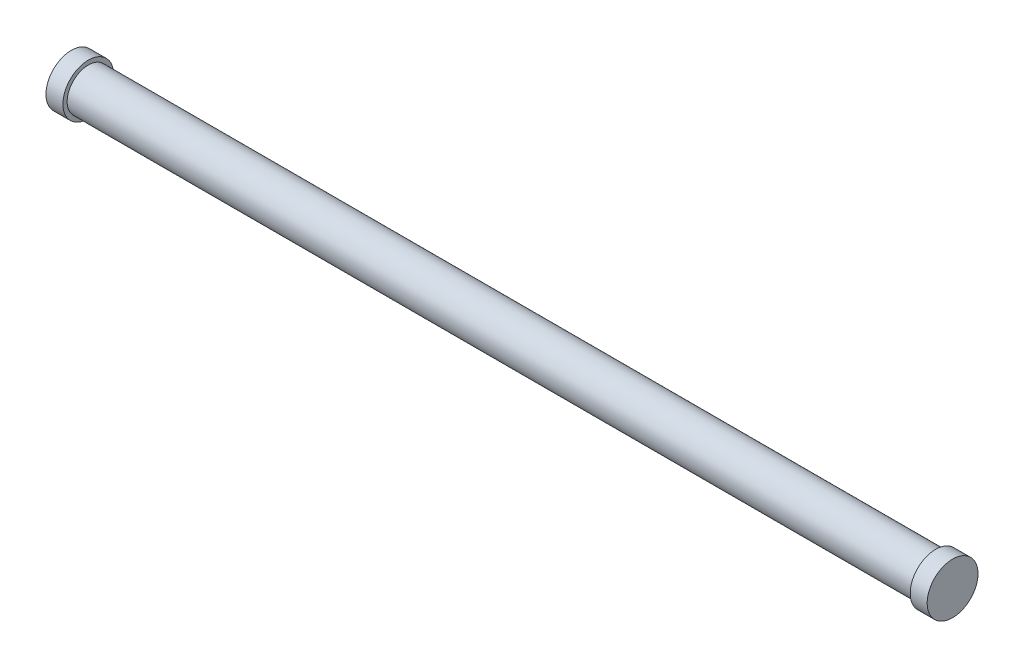
from build123d import *

# Parameters (mm, degrees)
SKETCH1_R           = 0.762
BOSS_EXTRUDE1_DEPTH = 0.508
SKETCH2_R           = 0.635
BOSS_EXTRUDE2_DEPTH = 25.4
SKETCH3_R           = 0.762
BOSS_EXTRUDE3_DEPTH = 0.508


with BuildPart() as part:
    # Sketch1 → Boss-Extrude1 (new body)
    with BuildSketch(Plane(origin=(0, 0, 0), x_dir=(0, 0, -1), z_dir=(1, 0, 0))):
        Circle(SKETCH1_R)
    extrude(amount=BOSS_EXTRUDE1_DEPTH)

    # Sketch2 → Boss-Extrude2 (add)
    with BuildSketch(Plane(origin=(0.508, 0, 0), x_dir=(0, 0, -1), z_dir=(1, 0, 0))):
        Circle(SKETCH2_R)
    extrude(amount=BOSS_EXTRUDE2_DEPTH)

    # Sketch3 → Boss-Extrude3 (add)
    with BuildSketch(Plane(origin=(25.908, 0, 0), x_dir=(0, 0, -1), z_dir=(1, 0, 0))):
        Circle(SKETCH3_R)
    extrude(amount=BOSS_EXTRUDE3_DEPTH)


solid = part.part
